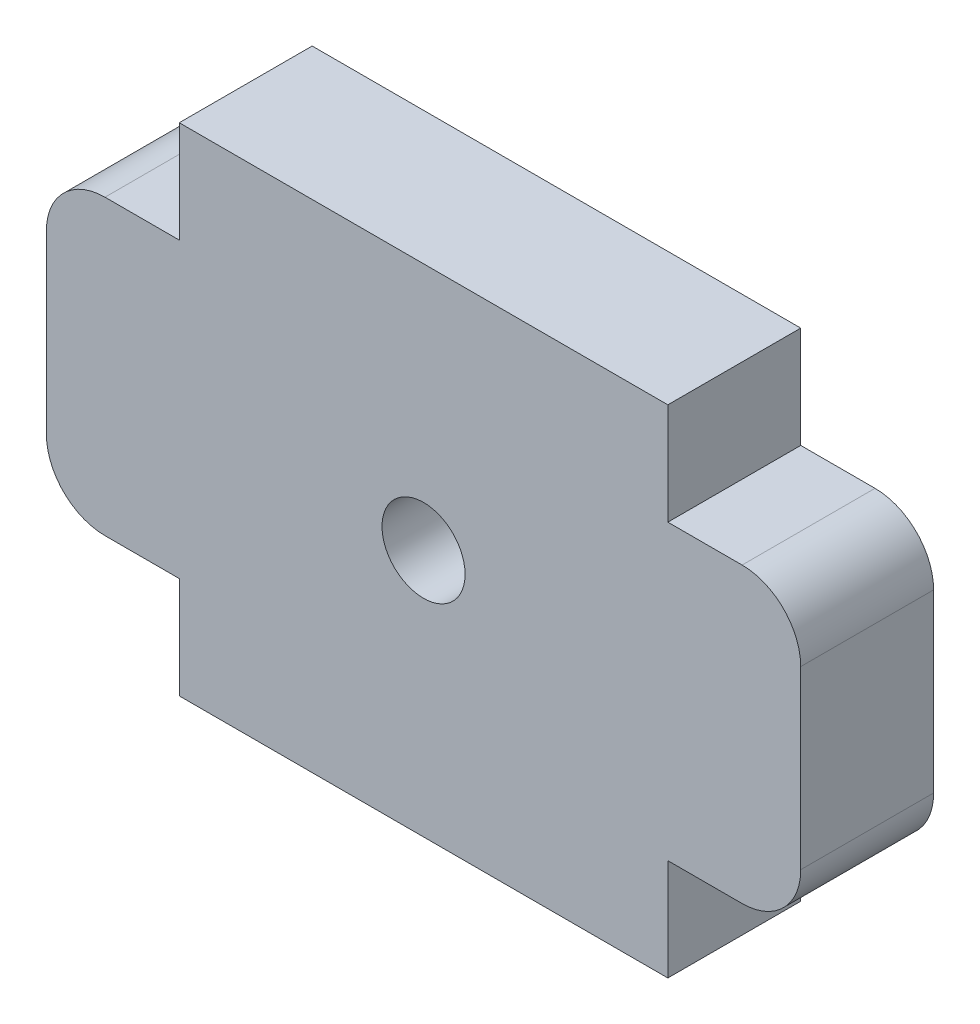
from build123d import *

# Parameters (mm, degrees)
SKETCH1_W            = 25
SKETCH1_H            = 25.4
BOSS_EXTRUDE1_DEPTH  = 6.8
SKETCH2_W            = 6.8
SKETCH2_H            = 15
BOSS_EXTRUDE2_DEPTH  = 6.8
FILLET1_R            = 3
FILLET1_OF_MIRROR1_R = 3
SKETCH3_R            = 2.125
CUT_EXTRUDE1_DEPTH   = 6.8


with BuildPart() as part:
    # Sketch1 → Boss-Extrude1 (new body)
    with BuildSketch(Plane.XY):
        Rectangle(SKETCH1_W, SKETCH1_H)
    extrude(amount=BOSS_EXTRUDE1_DEPTH)

    # Sketch2 → Boss-Extrude2 (add)
    with BuildSketch(Plane.XY.offset(6.8)):
        with Locations((15.9, 0)):
            Rectangle(SKETCH2_W, SKETCH2_H)
    boss_extrude2 = extrude(amount=-BOSS_EXTRUDE2_DEPTH)

    # Fillet1
    fillet1_edges = [part.edges().sort_by_distance(p)[0] for p in [
        (19.3, 7.5, 3.4),
        (19.3, -7.5, 3.4),
    ]]
    fillet(fillet1_edges, radius=FILLET1_R)

    # Mirror1: Boss-Extrude2 across plane
    add(boss_extrude2.mirror(Plane(origin=(0, 0, 0), x_dir=(0, 0, 1), z_dir=(1, 0, 0))))

    # Fillet1 of Mirror1
    fillet1_of_mirror1_edges = [part.edges().sort_by_distance(p)[0] for p in [
        (-19.3, 7.5, 3.4),
        (-19.3, -7.5, 3.4),
    ]]
    fillet(fillet1_of_mirror1_edges, radius=FILLET1_OF_MIRROR1_R)

    # Sketch3 → Cut-Extrude1 (cut)
    with BuildSketch(Plane.XY.offset(6.8)):
        Circle(SKETCH3_R)
    extrude(amount=-CUT_EXTRUDE1_DEPTH, mode=Mode.SUBTRACT)


solid = part.part
